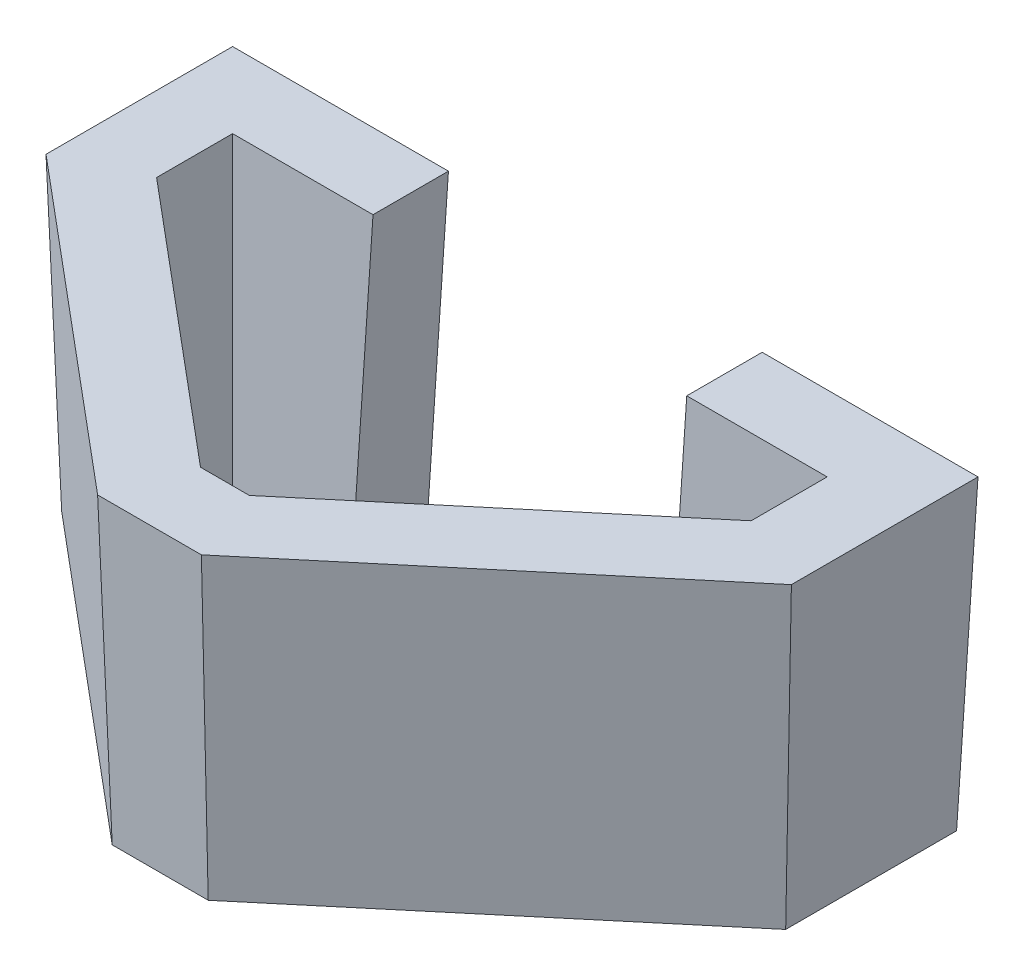
from build123d import *

# Parameters (mm, degrees)
SALIENTE_EXTRUIR1_DEPTH = 50.8
SALIENTE_EXTRUIR1_TAPER = -2
CORTAR_EXTRUIR1_DEPTH   = 50.8
CORTAR_EXTRUIR1_TAPER   = 2
CROQUIS5_W              = 52
CROQUIS5_H              = 12.5
CORTAR_EXTRUIR2_DEPTH   = 51.863129667


with BuildPart() as part:
    # Croquis2 → Saliente-Extruir1 (new body)
    with BuildSketch(Plane(origin=(0, 0, 0), x_dir=(1, 0, 0), z_dir=(0, 1, 0))):
        Polygon((-12.5, 12.5), (-12.5, -15.828845727), (39.545254998, -59.5), (55.454745002, -59.5), (107.5, -15.828845727), (107.5, 12.5), align=None)
    extrude(amount=SALIENTE_EXTRUIR1_DEPTH, taper=SALIENTE_EXTRUIR1_TAPER)

    # Croquis3 → Cortar-Extruir1 (cut)
    with BuildSketch(Plane(origin=(0, 50.8, 0), x_dir=(1, 0, 0), z_dir=(0, 1, 0))):
        Polygon((-1.77397509, 1.77397509), (-1.77397509, -10.82721817), (43.449208797, -48.77397509), (51.550791203, -48.77397509), (96.77397509, -10.82721817), (96.77397509, 1.77397509), align=None)
    extrude(amount=-CORTAR_EXTRUIR1_DEPTH, taper=CORTAR_EXTRUIR1_TAPER, mode=Mode.SUBTRACT)

    # Croquis5 → Cortar-Extruir2 (cut, through all, along a direction that is not the sketch's normal)
    with BuildSketch(Plane.XZ.offset(-50.8)):
        with Locations((47.5, -8.02397509)):
            Rectangle(CROQUIS5_W, CROQUIS5_H)
    extrude(amount=CORTAR_EXTRUIR2_DEPTH, dir=(-0.034878263, -0.998782766, 0.034878263), mode=Mode.SUBTRACT)


solid = part.part
